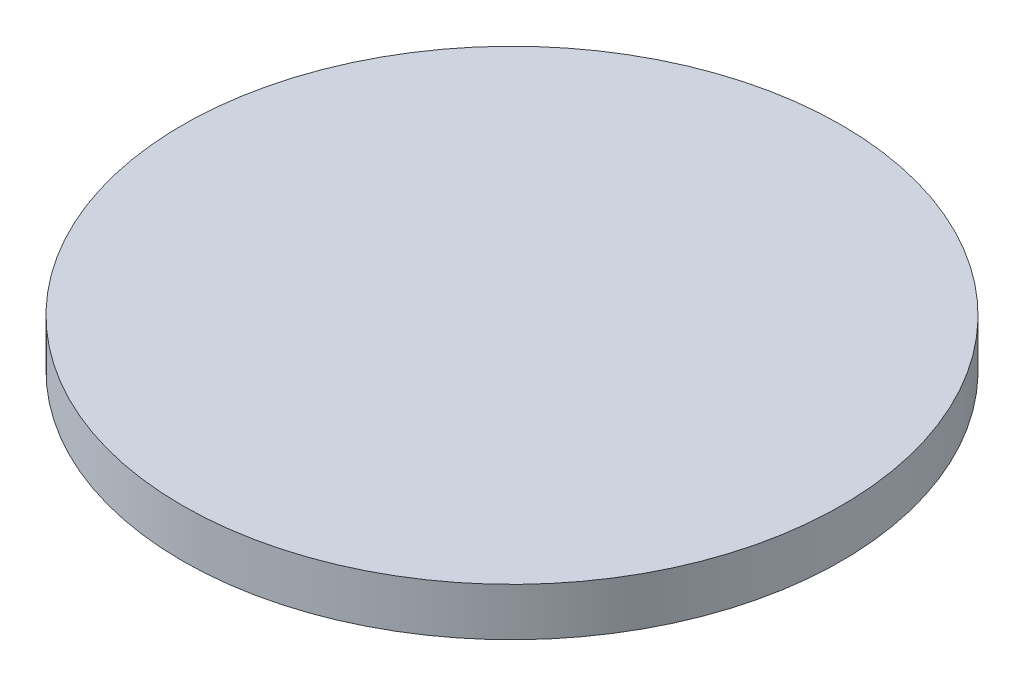
from build123d import *

# Parameters (mm, degrees)
SKETCH1_R           = 17.45
BOSS_EXTRUDE1_DEPTH = 2.54


with BuildPart() as part:
    # Sketch1 → Boss-Extrude1 (new body)
    with BuildSketch(Plane.XZ.offset(-14.478326304)):
        with Locations((91.816549827, 48.163081659)):
            Circle(SKETCH1_R)
    extrude(amount=BOSS_EXTRUDE1_DEPTH)


solid = part.part
